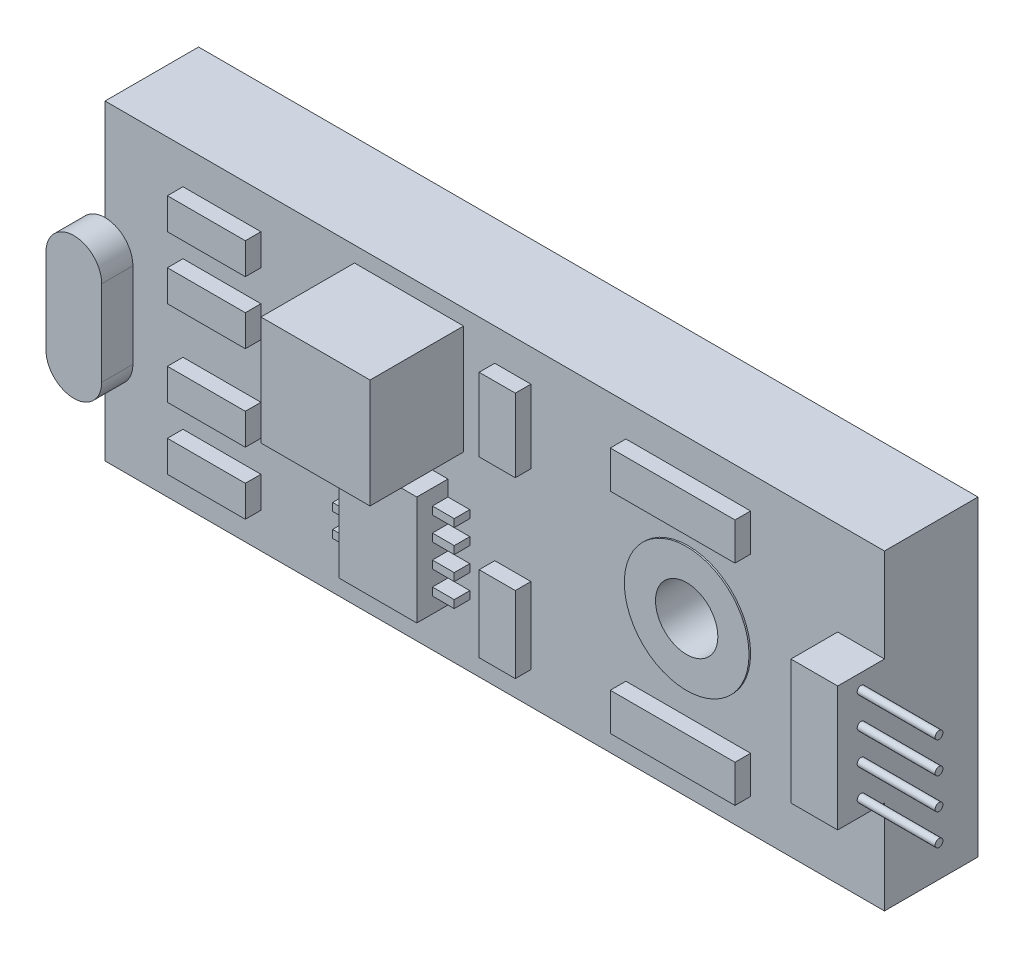
from build123d import *

# Parameters (mm, degrees)
CROQUIS1_W               = 25
CROQUIS1_H               = 10
SALIENTE_EXTRUIR1_DEPTH  = 3
CORTAR_EXTRUIR1_REACH    = 15.793
CROQUIS2_R               = 1
CROQUIS2_3_R             = 2
CROQUIS2_3_R_2           = 1
SALIENTE_EXTRUIR2_DEPTH  = 0.05
CROQUIS3_W               = 3.5
CROQUIS3_H               = 3.5
SALIENTE_EXTRUIR3_DEPTH  = 3
CROQUIS4_W               = 2.5
CROQUIS4_H               = 3.5
SALIENTE_EXTRUIR4_DEPTH  = 1
CROQUIS5_W               = 0.7
CROQUIS5_H               = 0.25
SALIENTE_EXTRUIR5_DEPTH  = 0.5
CROQUIS6_W               = 2.5
CROQUIS6_H               = 1
CROQUIS6_W_2             = 4
CROQUIS6_H_2             = 1.2
SALIENTE_EXTRUIR6_DEPTH  = 0.5
CROQUIS7_W               = 2.5
CROQUIS7_H               = 1
CROQUIS7_W_2             = 4
CROQUIS7_H_2             = 1.2
SALIENTE_EXTRUIR7_DEPTH  = 0.5
CROQUIS8_W               = 1.5
CROQUIS8_H               = 4
SALIENTE_EXTRUIR8_DEPTH  = 1.5
CROQUIS9_R               = 0.125
SALIENTE_EXTRUIR9_DEPTH  = 2.5
SALIENTE_EXTRUIR11_DEPTH = 1
CROQUIS12_W              = 1.159197975
CROQUIS12_H              = 2.351229057
CROQUIS12_H_2            = 2.446151106
SALIENTE_EXTRUIR12_DEPTH = 0.5


with BuildPart() as part:
    # Croquis1 → Saliente-Extruir1 (new body)
    with BuildSketch(Plane.XY):
        Rectangle(CROQUIS1_W, CROQUIS1_H)
    extrude(amount=SALIENTE_EXTRUIR1_DEPTH)

    # Croquis2 → Cortar-Extruir1 (cut, up to next)
    with BuildSketch(Plane.XY.offset(3), mode=Mode.PRIVATE) as cortar_extruir1_sk1:
        with Locations((6.205608074, 0)):
            Circle(CROQUIS2_R)
    cortar_extruir1_tool1 = extrude(cortar_extruir1_sk1.sketch, amount=-CORTAR_EXTRUIR1_REACH, mode=Mode.PRIVATE) & part.part
    add(cortar_extruir1_tool1.solids().sort_by_distance((6.205608, 0, 3))[0], mode=Mode.SUBTRACT)

    # Croquis2_3 → Saliente-Extruir2 (add, symmetric)
    with BuildSketch(Plane.XY.offset(3)):
        with Locations((6.205608074, 0)):
            Circle(CROQUIS2_3_R)
        with Locations((6.205608074, 0)):
            Circle(CROQUIS2_3_R_2, mode=Mode.SUBTRACT)
    extrude(amount=SALIENTE_EXTRUIR2_DEPTH, both=True)

    # Croquis3 → Saliente-Extruir3 (add)
    with BuildSketch(Plane.XY.offset(3)):
        with Locations((-2.75, 2.75)):
            Rectangle(CROQUIS3_W, CROQUIS3_H)
    extrude(amount=SALIENTE_EXTRUIR3_DEPTH)

    # Croquis4 → Saliente-Extruir4 (add)
    with BuildSketch(Plane.XY.offset(3)):
        with Locations((-2.75, -1.75)):
            Rectangle(CROQUIS4_W, CROQUIS4_H)
    extrude(amount=SALIENTE_EXTRUIR4_DEPTH)

    # Croquis5 → Saliente-Extruir5 (add)
    with BuildSketch(Plane.XY.offset(3)):
        with Locations((-4.35, -0.625)):
            Rectangle(CROQUIS5_W, CROQUIS5_H)
        with Locations((-4.35, -1.375)):
            Rectangle(CROQUIS5_W, CROQUIS5_H)
        with Locations((-4.35, -2.125)):
            Rectangle(CROQUIS5_W, CROQUIS5_H)
        with Locations((-4.35, -2.875)):
            Rectangle(CROQUIS5_W, CROQUIS5_H)
        with Locations((-1.15, -2.875)):
            Rectangle(CROQUIS5_W, CROQUIS5_H)
        with Locations((-1.15, -2.125)):
            Rectangle(CROQUIS5_W, CROQUIS5_H)
        with Locations((-1.15, -1.375)):
            Rectangle(CROQUIS5_W, CROQUIS5_H)
        with Locations((-1.15, -0.625)):
            Rectangle(CROQUIS5_W, CROQUIS5_H)
    extrude(amount=SALIENTE_EXTRUIR5_DEPTH)

    # Croquis6 → Saliente-Extruir6 (add)
    with BuildSketch(Plane.XY.offset(3)):
        with Locations((-8.75, 3.368697132)):
            Rectangle(CROQUIS6_W, CROQUIS6_H)
        with Locations((-8.75, 1.368697132)):
            Rectangle(CROQUIS6_W, CROQUIS6_H)
        with Locations((6.205608074, -3.364903889)):
            Rectangle(CROQUIS6_W_2, CROQUIS6_H_2)
    extrude(amount=SALIENTE_EXTRUIR6_DEPTH)

    # Croquis7 → Saliente-Extruir7 (add)
    with BuildSketch(Plane.XY.offset(3)):
        with Locations((-8.75, -1.368697132)):
            Rectangle(CROQUIS7_W, CROQUIS7_H)
        with Locations((6.205608074, 3.364903889)):
            Rectangle(CROQUIS7_W_2, CROQUIS7_H_2)
        with Locations((-8.75, -3.368697132)):
            Rectangle(CROQUIS7_W, CROQUIS7_H)
        with Locations((6.205608074, -3.364903889)):
            Rectangle(CROQUIS7_W_2, CROQUIS7_H_2)
    extrude(amount=SALIENTE_EXTRUIR7_DEPTH)



with BuildPart() as body_2:
    # Croquis8 → Saliente-Extruir8 (new body)
    with BuildSketch(Plane.XY.offset(3)):
        with Locations((11.75, 0)):
            Rectangle(CROQUIS8_W, CROQUIS8_H)
    extrude(amount=SALIENTE_EXTRUIR8_DEPTH)


with BuildPart() as part_1:
    add(part.part)

    add(body_2.part)  # Saliente-Extruir9 merges body 2
    # Croquis9 → Saliente-Extruir9 (add)
    with BuildSketch(Plane(origin=(12.5, 0, 0), x_dir=(0, 0, -1), z_dir=(1, 0, 0))):
        with Locations(Location((-3.75, 1.514222449, 0), (0, 0, 180))):
            Circle(CROQUIS9_R)
        with Locations(Location((-3.75, 0.514222449, 0), (0, 0, 180))):
            Circle(CROQUIS9_R)
        with Locations(Location((-3.75, -0.485777551, 0), (0, 0, 180))):
            Circle(CROQUIS9_R)
        with Locations(Location((-3.75, -1.485777551, 0), (0, 0, 180))):
            Circle(CROQUIS9_R)
    extrude(amount=SALIENTE_EXTRUIR9_DEPTH)

    # Croquis11 → Saliente-Extruir11 (add)
    with BuildSketch(Plane.XY.offset(3)):
        with BuildLine():
            Line((-11.606480583, 0.868697132), (-11.606480583, -1.868697132))
            ThreePointArc((-11.606480583, -1.868697132), (-12.5, -2.762216549), (-13.393519417, -1.868697132))
            Line((-13.393519417, -1.868697132), (-13.393519417, 0.868697132))
            ThreePointArc((-13.393519417, 0.868697132), (-12.5, 1.762216549), (-11.606480583, 0.868697132))
        make_face()
    extrude(amount=SALIENTE_EXTRUIR11_DEPTH)

    # Croquis12 → Saliente-Extruir12 (add)
    with BuildSketch(Plane.XY.offset(3)):
        with Locations((0.579598988, 2.789289361)):
            Rectangle(CROQUIS12_W, CROQUIS12_H)
        with Locations((0.579598988, -2.741828336)):
            Rectangle(CROQUIS12_W, CROQUIS12_H_2)
    extrude(amount=SALIENTE_EXTRUIR12_DEPTH)


solid = part_1.part
